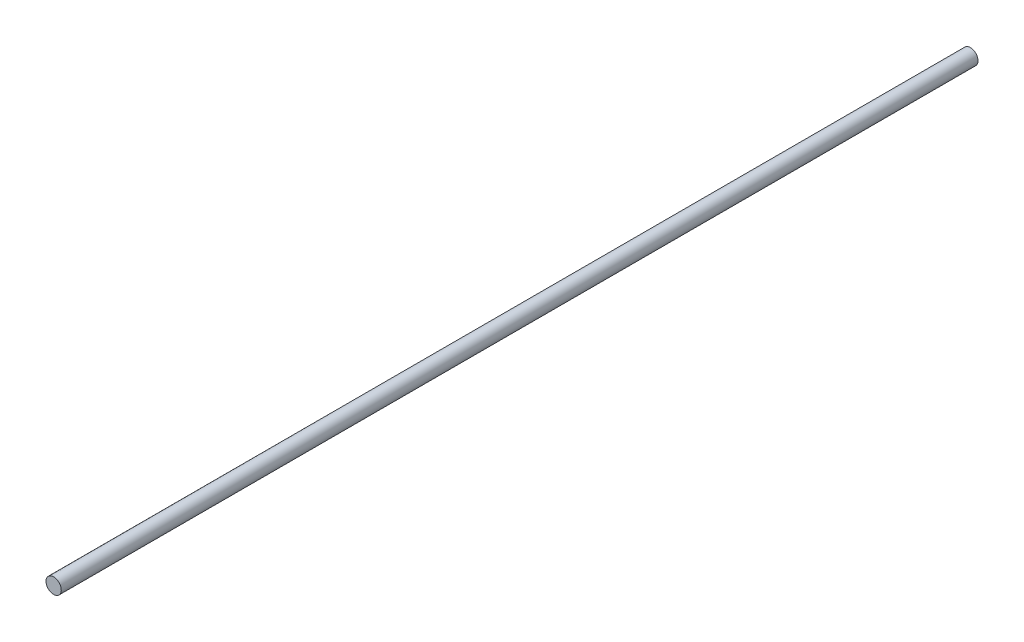
from build123d import *

# Parameters (mm, degrees)
SKETCH_1_R      = 1.25
EXTRUDE_1_DEPTH = 150


with BuildPart() as part:
    # ｽｹｯﾁ1 → ﾎﾞｽ - 押し出し1 (new body)
    with BuildSketch(Plane.XY):
        Circle(SKETCH_1_R)
    extrude(amount=EXTRUDE_1_DEPTH)


solid = part.part
